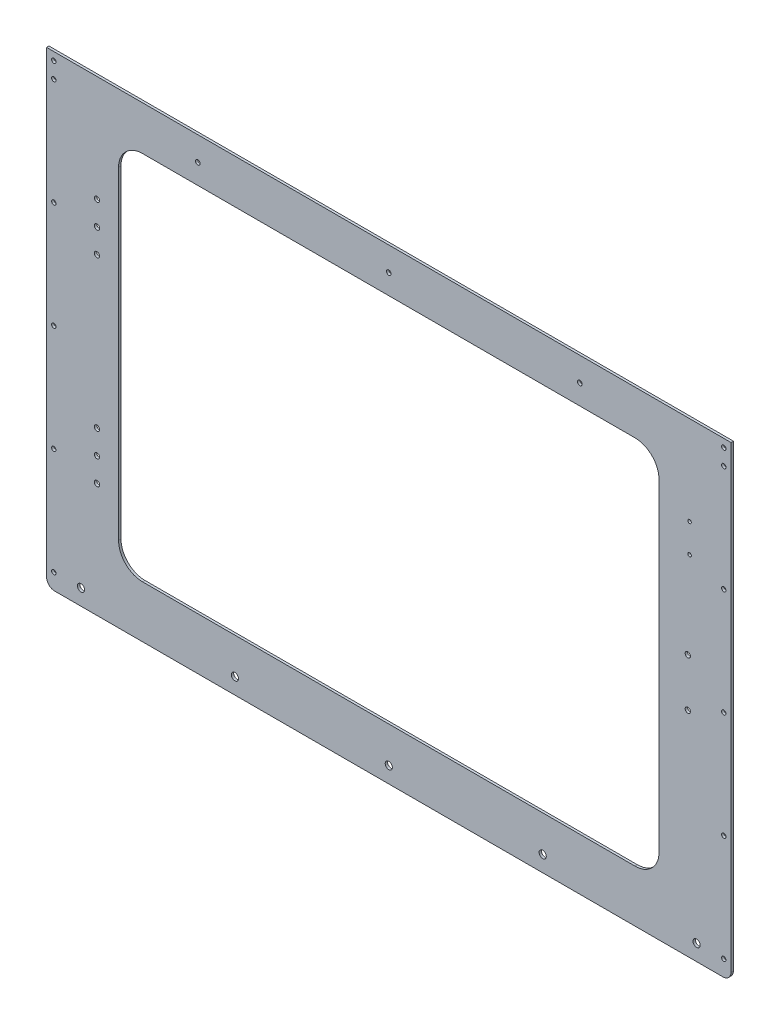
from build123d import *

# Parameters (mm, degrees)
SKETCH1_W            = 856
SKETCH1_H            = 543.9
MAINFRONT_DEPTH      = 3
SKETCH2_W            = 676
SKETCH2_H            = 463.9
DOORCUT_DEPTH        = 4
DOORROUNDINTERNAL_R  = 30
SKETCH3_W            = 856
SKETCH3_H            = 40
BOTTOMMOUNT_DEPTH    = 3
M8_CLEARANCE_HOLE1_D = 9
LPATTERN1_COUNT      = 5
LPATTERN1_PITCH      = 192.5
M5_CLEARANCE_HOLE1_D = 5.5
LPATTERN2_COUNT      = 5
LPATTERN2_PITCH      = 133.475
MIRROR1_COPY_1_D     = 5.5
MIRROR1_COPY_2_D     = 5.5
MIRROR1_COPY_3_D     = 5.5
MIRROR1_COPY_4_D     = 5.5
M5_CLEARANCE_HOLE2_D = 5.5
LPATTERN3_COUNT      = 2
LPATTERN3_PITCH      = 838
M6_CLEARANCE_HOLE1_D = 6.6
FILLET1_R            = 10
M4_CLEARANCE_HOLE1_D = 4.5
M6_CLEARANCE_HOLE2_D = 6.6
M5_CLEARANCE_HOLE3_D = 5.8


with BuildPart() as part:
    # Sketch1 → MainFront (new body)
    with BuildSketch(Plane.XY):
        with Locations((428, 271.95)):
            Rectangle(SKETCH1_W, SKETCH1_H)
    extrude(amount=MAINFRONT_DEPTH)

    # Sketch2 → DoorCut (cut, through all)
    with BuildSketch(Plane.XY.offset(3)):
        with Locations((428, 256.95)):
            Rectangle(SKETCH2_W, SKETCH2_H)
    extrude(amount=-DOORCUT_DEPTH, mode=Mode.SUBTRACT)

    # DoorRoundInternal
    doorroundinternal_edges = [part.edges().sort_by_distance(p)[0] for p in [
        (766, 488.9, 1.5),
        (766, 25, 1.5),
        (90, 25, 1.5),
        (90, 488.9, 1.5),
    ]]
    fillet(doorroundinternal_edges, radius=DOORROUNDINTERNAL_R)

    # Sketch3 → BottomMount (add)
    with BuildSketch(Plane.XY.offset(3)):
        with Locations((428, -20)):
            Rectangle(SKETCH3_W, SKETCH3_H)
    extrude(amount=-BOTTOMMOUNT_DEPTH)

    # M8 Clearance Hole1 (through all)
    with Locations(Plane.XY.offset(3)):
        with Locations((43, -20)):
            m8_clearance_hole1 = Hole(M8_CLEARANCE_HOLE1_D / 2)

    # LPattern1: M8 Clearance Hole1 ×5
    with Locations(*[(i * LPATTERN1_PITCH, 0, 0) for i in range(1, LPATTERN1_COUNT)]):
        add(m8_clearance_hole1, mode=Mode.SUBTRACT)

    # M5 Clearance Hole1 (through all)
    with Locations(Plane.XY.offset(3)):
        with Locations((9, -20)):
            m5_clearance_hole1 = Hole(M5_CLEARANCE_HOLE1_D / 2)

    # LPattern2: M5 Clearance Hole1 ×5
    with Locations(*[(0, i * LPATTERN2_PITCH, 0) for i in range(1, LPATTERN2_COUNT)]):
        add(m5_clearance_hole1, mode=Mode.SUBTRACT)

    # Mirror1: M5 Clearance Hole1 across plane
    add(m5_clearance_hole1.mirror(Plane(origin=(428, 0, 0), x_dir=(0, 0, 1), z_dir=(1, 0, 0))), mode=Mode.SUBTRACT)

    # Mirror1 copy 1 (through all)
    with Locations(Plane(origin=(856, 133.475, 3), x_dir=(-1, 0, 0), z_dir=(0, 0, 1))):
        with Locations((9, 20)):
            Hole(MIRROR1_COPY_1_D / 2)

    # Mirror1 copy 2 (through all)
    with Locations(Plane(origin=(856, 266.95, 3), x_dir=(-1, 0, 0), z_dir=(0, 0, 1))):
        with Locations((9, 20)):
            Hole(MIRROR1_COPY_2_D / 2)

    # Mirror1 copy 3 (through all)
    with Locations(Plane(origin=(856, 400.425, 3), x_dir=(-1, 0, 0), z_dir=(0, 0, 1))):
        with Locations((9, 20)):
            Hole(MIRROR1_COPY_3_D / 2)

    # Mirror1 copy 4 (through all)
    with Locations(Plane(origin=(856, 533.9, 3), x_dir=(-1, 0, 0), z_dir=(0, 0, 1))):
        with Locations((9, 20)):
            Hole(MIRROR1_COPY_4_D / 2)

    # M5 Clearance Hole2 (through all)
    with Locations(Plane.XY.offset(3)):
        with Locations((9, 533.9)):
            m5_clearance_hole2 = Hole(M5_CLEARANCE_HOLE2_D / 2)

    # LPattern3: M5 Clearance Hole2 ×2
    with Locations(*[(i * LPATTERN3_PITCH, 0, 0) for i in range(1, LPATTERN3_COUNT)]):
        add(m5_clearance_hole2, mode=Mode.SUBTRACT)

    # M6 Clearance Hole1 (through all)
    with Locations(Plane.XY.offset(3)):
        with Locations((802, 286.95), (802, 226.95)):
            Hole(M6_CLEARANCE_HOLE1_D / 2)

    # Fillet1
    fillet1_edges = [part.edges().sort_by_distance(p)[0] for p in [
        (0, -40, 1.5),
        (856, -40, 1.5),
    ]]
    fillet(fillet1_edges, radius=FILLET1_R)

    # M4 Clearance Hole1 (through all)
    with Locations(Plane.XY.offset(3)):
        with Locations((804.180642757, 432.408967428), (804.180642757, 396.408967428)):
            Hole(M4_CLEARANCE_HOLE1_D / 2)

    # M6 Clearance Hole2 (through all)
    with Locations(Plane.XY.offset(3)):
        with Locations((63, 410.9), (63, 380.9), (63, 350.9)):
            m6_clearance_hole2 = Hole(M6_CLEARANCE_HOLE2_D / 2)

    # Mirror2: M6 Clearance Hole2 across plane
    add(m6_clearance_hole2.mirror(Plane.ZX.offset(256.95)), mode=Mode.SUBTRACT)

    # M5 Clearance Hole3 (through all)
    with Locations(Plane.XY.offset(3)):
        with Locations((189, 513.9), (428, 513.9), (667, 513.9)):
            Hole(M5_CLEARANCE_HOLE3_D / 2)


solid = part.part
